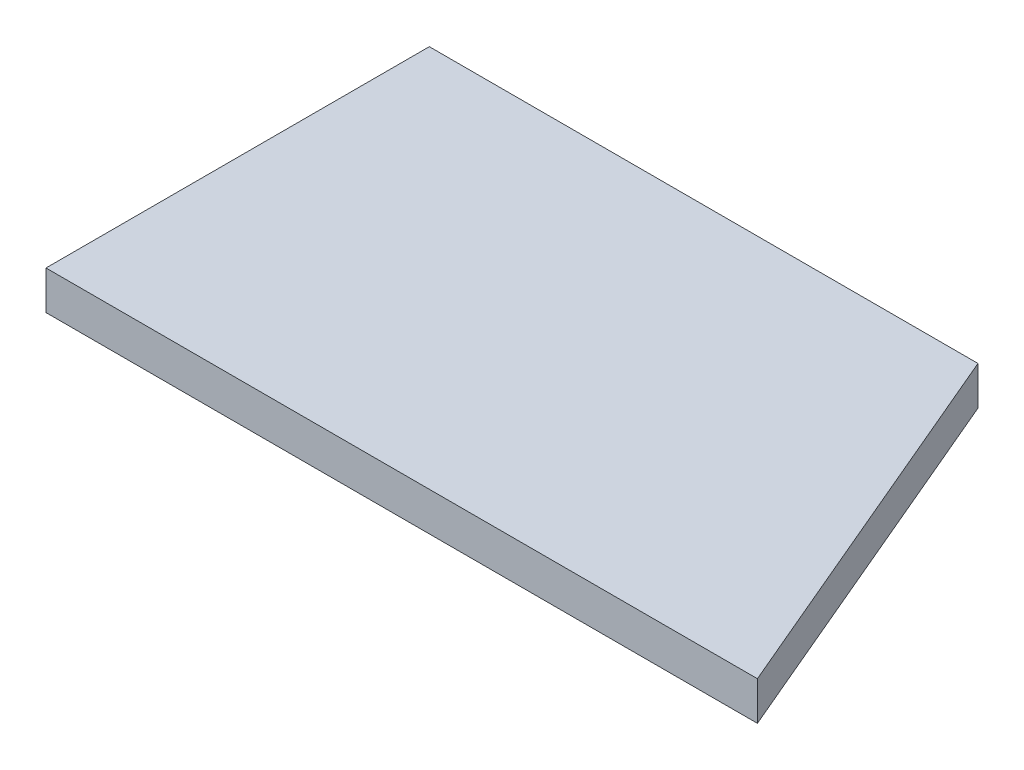
from build123d import *

# Parameters (mm, degrees)
EXTRUDE_1_DEPTH = 5


with BuildPart() as part:
    # Эскиз1 → Бобышка-Вытянуть1 (new body)
    with BuildSketch(Plane(origin=(0, 0, 0), x_dir=(1, 0, 0), z_dir=(0, 1, 0))):
        Polygon((0, 0), (92, 0), (70.958484778, 49.570703416), (0, 49.570703416), align=None)
    extrude(amount=EXTRUDE_1_DEPTH)


solid = part.part
